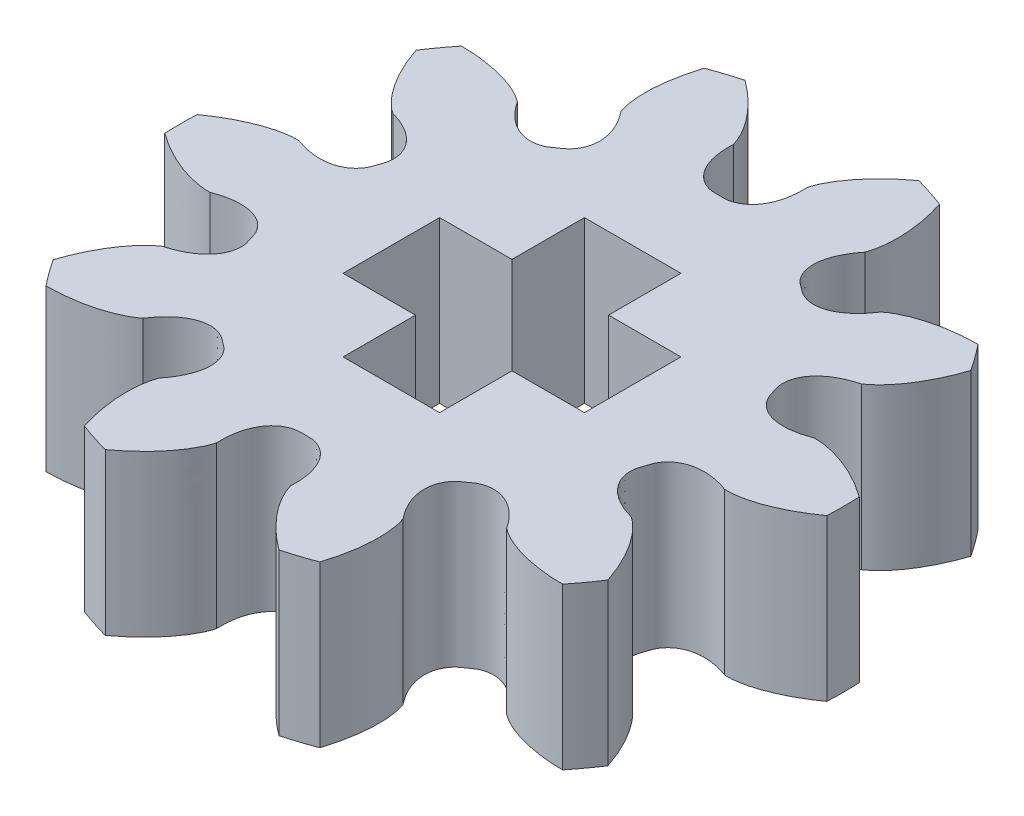
from build123d import *

# Parameters (mm, degrees)
BOSS_EXTRUDE1_DEPTH = 3


with BuildPart() as part:
    # Sketch1 → Boss-Extrude1 (new body)
    with BuildSketch(Plane(origin=(0, 0, 0), x_dir=(1, 0, 0), z_dir=(0, 1, 0))):
        with BuildLine():
            ThreePointArc((-2.195246041, -5.776962421), (-1.909725025, -5.877529271), (-1.61962196, -5.963994023))
            add(Edge.make_bspline(
                [(-1.61962196, -5.963994023), (-1.56984541, -5.926389713), (-1.470292055, -5.851180902), (-1.328761717, -5.728585248), (-1.193841186, -5.598826433), (-1.067209813, -5.460903424), (-0.950188009, -5.314730698), (-0.862420789, -5.185625903), (-0.799625352, -5.077784513), (-0.757179661, -4.994397549), (-0.719216402, -4.908719156), (-0.701057464, -4.849011857), (-0.691979526, -4.819163245)],
                knots=[0, 0, 0, 0, 0.010251706, 0.020503464, 0.030755047, 0.041006321, 0.051257106, 0.061507029, 0.066633012, 0.071758798, 0.07688417, 0.082007812, 0.082007812, 0.082007812, 0.082007812], degree=3, weights=[1, 1, 1, 1, 1, 1, 1, 1, 1, 1, 1, 1, 1]))
            add(Edge.make_bspline(
                [(-0.691979526, -4.819163245), (-0.692972091, -4.791041216), (-0.694957195, -4.734797907), (-0.692841973, -4.650377022), (-0.686110642, -4.566172646), (-0.672709266, -4.482813678), (-0.656279018, -4.399951189), (-0.631093663, -4.319279083), (-0.600480092, -4.240553587), (-0.562043943, -4.165226452), (-0.515300654, -4.094752352), (-0.460694656, -4.030167229), (-0.397849492, -3.973436024), (-0.327051342, -3.927084247), (-0.250353587, -3.891173269), (-0.182193787, -3.872913739), (-0.126636908, -3.863689308), (-0.070311712, -3.861657298), (0, -3.863061836), (0.070311712, -3.861657298), (0.126636908, -3.863689308), (0.182193787, -3.872913739), (0.250353587, -3.891173269), (0.327051342, -3.927084247), (0.397849492, -3.973436024), (0.460694656, -4.030167229), (0.515300654, -4.094752352), (0.562043943, -4.165226452), (0.600480092, -4.240553587), (0.631093663, -4.319279083), (0.656279018, -4.399951189), (0.672709266, -4.482813678), (0.686110642, -4.566172646), (0.692841973, -4.650377022), (0.694957195, -4.734797907), (0.692972091, -4.791041216), (0.691979526, -4.819163245)],
                knots=[0, 0, 0, 0, 0.003643402, 0.007286706, 0.010929975, 0.01457286, 0.01821558, 0.021858686, 0.025500936, 0.029144127, 0.032787024, 0.036428762, 0.040069815, 0.043709849, 0.04734977, 0.050988094, 0.052810356, 0.054631699, 0.058275045, 0.061918391, 0.063739733, 0.065561995, 0.069200319, 0.07284024, 0.076480275, 0.080121327, 0.083763065, 0.087405962, 0.091049153, 0.094691403, 0.098334509, 0.101977229, 0.105620114, 0.109263383, 0.112906688, 0.116550089, 0.116550089, 0.116550089, 0.116550089], degree=3, weights=[1, 1, 1, 1, 1, 1, 1, 1, 1, 1, 1, 1, 1, 1, 1, 1, 1, 1, 1, 1, 1, 1, 1, 1, 1, 1, 1, 1, 1, 1, 1, 1, 1, 1, 1, 1, 1]))
            add(Edge.make_bspline(
                [(0.691979526, -4.819163245), (0.701057464, -4.849011857), (0.719216402, -4.908719156), (0.757179661, -4.994397549), (0.799625352, -5.077784513), (0.862420789, -5.185625903), (0.950188009, -5.314730698), (1.067209813, -5.460903424), (1.193841186, -5.598826433), (1.328761717, -5.728585248), (1.470292055, -5.851180902), (1.56984541, -5.926389713), (1.61962196, -5.963994023)],
                knots=[0, 0, 0, 0, 0.002373455, 0.004747711, 0.007122158, 0.009496697, 0.014244829, 0.01899336, 0.023742117, 0.028491018, 0.03324, 0.037988957, 0.037988957, 0.037988957, 0.037988957], degree=3, weights=[1, 1, 1, 1, 1, 1, 1, 1, 1, 1, 1, 1, 1]))
            ThreePointArc((1.61962196, -5.963994023), (1.909725025, -5.877529271), (2.195246041, -5.776962421))
            add(Edge.make_bspline(
                [(2.195246041, -5.776962421), (2.213412858, -5.717281974), (2.249746584, -5.597920774), (2.292187114, -5.415549361), (2.3250698, -5.231267976), (2.346447621, -5.045253864), (2.355202077, -4.858213954), (2.350321355, -4.702177703), (2.337736353, -4.578021954), (2.32306201, -4.485611532), (2.303414436, -4.393982012), (2.283010256, -4.335004236), (2.272809887, -4.305520324)],
                knots=[0, 0, 0, 0, 0.018166013, 0.036332118, 0.054497913, 0.072663161, 0.090827541, 0.108990394, 0.11807363, 0.127156519, 0.136238672, 0.145317761, 0.145317761, 0.145317761, 0.145317761], degree=3, weights=[1, 1, 1, 1, 1, 1, 1, 1, 1, 1, 1, 1, 1]))
            add(Edge.make_bspline(
                [(2.272809887, -4.305520324), (2.255477171, -4.28335254), (2.220812201, -4.239017561), (2.1729021, -4.169476335), (2.128853771, -4.097396987), (2.09069854, -4.022081034), (2.055285541, -3.945386415), (2.028243047, -3.86531773), (2.006736261, -3.78363326), (1.99355558, -3.700100126), (1.989948058, -3.615610366), (1.996163056, -3.531263303), (2.013660096, -3.448427333), (2.043692111, -3.369313849), (2.084633955, -3.295179449), (2.129043709, -3.240343854), (2.168568184, -3.200225618), (2.212941839, -3.165474568), (2.270650776, -3.125282675), (2.326708579, -3.082818193), (2.373471005, -3.051355004), (2.42383945, -3.026162211), (2.489714569, -3.000871156), (2.572872298, -2.984841938), (2.657394096, -2.980727206), (2.741582667, -2.989684254), (2.823722031, -3.009838116), (2.902961782, -3.039377844), (2.978333459, -3.077726575), (3.049374044, -3.123422634), (3.117167299, -3.173884158), (3.179164997, -3.231263862), (3.23900411, -3.290825553), (3.293943962, -3.354991747), (3.345276563, -3.422046381), (3.376729568, -3.468714989), (3.39245628, -3.492049603)],
                knots=[0, 0, 0, 0, 0.008194405, 0.016388591, 0.024582696, 0.03277594, 0.040968812, 0.04916255, 0.057354364, 0.065548295, 0.073741565, 0.081932227, 0.090121349, 0.09830818, 0.106494756, 0.114677741, 0.118776206, 0.122872602, 0.131066881, 0.139261161, 0.143357557, 0.147456021, 0.155639006, 0.163825582, 0.172012413, 0.180201535, 0.188392198, 0.196585467, 0.204779398, 0.212971212, 0.221164951, 0.229357823, 0.237551066, 0.245745171, 0.253939358, 0.262133762, 0.262133762, 0.262133762, 0.262133762], degree=3, weights=[1, 1, 1, 1, 1, 1, 1, 1, 1, 1, 1, 1, 1, 1, 1, 1, 1, 1, 1, 1, 1, 1, 1, 1, 1, 1, 1, 1, 1, 1, 1, 1, 1, 1, 1, 1, 1]))
            add(Edge.make_bspline(
                [(3.39245628, -3.492049603), (3.41734506, -3.51086176), (3.467131019, -3.548492423), (3.548204437, -3.595493456), (3.63155735, -3.638005976), (3.745747504, -3.688341261), (3.892638571, -3.741200956), (4.073229372, -3.790673485), (4.256745415, -3.827823491), (4.442168736, -3.853496278), (4.628729102, -3.869488801), (4.753476088, -3.871818013), (4.815849422, -3.872982616)],
                knots=[0, 0, 0, 0, 0.009079089, 0.018161243, 0.027244131, 0.036327367, 0.05449022, 0.072654601, 0.090819848, 0.108985643, 0.127151749, 0.145317761, 0.145317761, 0.145317761, 0.145317761], degree=3, weights=[1, 1, 1, 1, 1, 1, 1, 1, 1, 1, 1, 1, 1]))
            ThreePointArc((4.815849422, -3.872982616), (4.999725025, -3.632512859), (5.171604669, -3.383327527))
            add(Edge.make_bspline(
                [(5.171604669, -3.383327527), (5.151222645, -3.324366843), (5.110458494, -3.206445175), (5.037598377, -3.033957685), (4.955883148, -2.865542955), (4.863841818, -2.70248881), (4.76098502, -2.546024604), (4.665320626, -2.422657442), (4.582162227, -2.32961061), (4.515972951, -2.26347437), (4.446219249, -2.200893085), (4.395045654, -2.165172339), (4.369463173, -2.147314979)],
                knots=[0, 0, 0, 0, 0.018166013, 0.036332118, 0.054497913, 0.072663161, 0.090827541, 0.108990394, 0.11807363, 0.127156519, 0.136238672, 0.145317761, 0.145317761, 0.145317761, 0.145317761], degree=3, weights=[1, 1, 1, 1, 1, 1, 1, 1, 1, 1, 1, 1, 1]))
            add(Edge.make_bspline(
                [(4.369463173, -2.147314979), (4.342410816, -2.13956878), (4.288306819, -2.124076587), (4.208671426, -2.095977404), (4.130668401, -2.063554944), (4.055530564, -2.02505014), (3.98180088, -1.983818129), (3.912859851, -1.934936381), (3.847447569, -1.881493628), (3.787684629, -1.821661313), (3.735104248, -1.75542811), (3.690554327, -1.683536818), (3.656019968, -1.606236609), (3.63381464, -1.52458008), (3.623362181, -1.440539079), (3.627058872, -1.370072752), (3.635453937, -1.314384514), (3.650926823, -1.260188143), (3.673990132, -1.193751758), (3.69438185, -1.126447319), (3.71371985, -1.073506801), (3.739660825, -1.023519574), (3.778089207, -0.964338258), (3.835943485, -0.902491461), (3.901904477, -0.849481906), (3.975279283, -0.807243509), (4.053577567, -0.77526802), (4.135046889, -0.752590205), (4.218564675, -0.73931262), (4.302897184, -0.734524899), (4.38740362, -0.735501255), (4.471287755, -0.745481078), (4.554708098, -0.75849495), (4.636871315, -0.778113657), (4.717813986, -0.802189449), (4.770691121, -0.821457534), (4.79713004, -0.831091704)],
                knots=[0, 0, 0, 0, 0.008194405, 0.016388591, 0.024582696, 0.03277594, 0.040968812, 0.04916255, 0.057354364, 0.065548295, 0.073741565, 0.081932227, 0.090121349, 0.09830818, 0.106494756, 0.114677741, 0.118776206, 0.122872602, 0.131066881, 0.139261161, 0.143357557, 0.147456021, 0.155639006, 0.163825582, 0.172012413, 0.180201535, 0.188392198, 0.196585467, 0.204779398, 0.212971212, 0.221164951, 0.229357823, 0.237551066, 0.245745171, 0.253939358, 0.262133762, 0.262133762, 0.262133762, 0.262133762], degree=3, weights=[1, 1, 1, 1, 1, 1, 1, 1, 1, 1, 1, 1, 1, 1, 1, 1, 1, 1, 1, 1, 1, 1, 1, 1, 1, 1, 1, 1, 1, 1, 1, 1, 1, 1, 1, 1, 1]))
            add(Edge.make_bspline(
                [(4.79713004, -0.831091704), (4.828322995, -0.831681801), (4.89071943, -0.832862194), (4.983935717, -0.823233069), (5.076357873, -0.808632807), (5.198325986, -0.782235619), (5.348233505, -0.738659608), (5.523413755, -0.672535115), (5.693717578, -0.594722077), (5.858818282, -0.506502705), (6.019148957, -0.409783497), (6.121440465, -0.33834343), (6.172586089, -0.302623488)],
                knots=[0, 0, 0, 0, 0.009079089, 0.018161243, 0.027244131, 0.036327367, 0.05449022, 0.072654601, 0.090819848, 0.108985643, 0.127151749, 0.145317761, 0.145317761, 0.145317761, 0.145317761], degree=3, weights=[1, 1, 1, 1, 1, 1, 1, 1, 1, 1, 1, 1, 1]))
            ThreePointArc((6.172586089, -0.302623488), (6.18, 0), (6.172586089, 0.302623488))
            add(Edge.make_bspline(
                [(6.172586089, 0.302623488), (6.121440465, 0.33834343), (6.019148957, 0.409783497), (5.858818282, 0.506502705), (5.693717578, 0.594722077), (5.523413755, 0.672535115), (5.348233505, 0.738659608), (5.198325986, 0.782235619), (5.076357873, 0.808632807), (4.983935717, 0.823233069), (4.89071943, 0.832862194), (4.828322995, 0.831681801), (4.79713004, 0.831091704)],
                knots=[0, 0, 0, 0, 0.018166013, 0.036332118, 0.054497913, 0.072663161, 0.090827541, 0.108990394, 0.11807363, 0.127156519, 0.136238672, 0.145317761, 0.145317761, 0.145317761, 0.145317761], degree=3, weights=[1, 1, 1, 1, 1, 1, 1, 1, 1, 1, 1, 1, 1]))
            add(Edge.make_bspline(
                [(4.79713004, 0.831091704), (4.770691121, 0.821457534), (4.717813986, 0.802189449), (4.636871315, 0.778113657), (4.554708098, 0.75849495), (4.471287755, 0.745481078), (4.38740362, 0.735501255), (4.302897184, 0.734524899), (4.218564675, 0.73931262), (4.135046889, 0.752590205), (4.053577567, 0.77526802), (3.975279283, 0.807243509), (3.901904477, 0.849481906), (3.835943485, 0.902491461), (3.778089207, 0.964338258), (3.739660825, 1.023519574), (3.71371985, 1.073506801), (3.69438185, 1.126447319), (3.673990132, 1.193751758), (3.650926823, 1.260188143), (3.635453937, 1.314384514), (3.627058872, 1.370072752), (3.623362181, 1.440539079), (3.63381464, 1.52458008), (3.656019968, 1.606236609), (3.690554327, 1.683536818), (3.735104248, 1.75542811), (3.787684629, 1.821661313), (3.847447569, 1.881493628), (3.912859851, 1.934936381), (3.98180088, 1.983818129), (4.055530564, 2.02505014), (4.130668401, 2.063554944), (4.208671426, 2.095977404), (4.288306819, 2.124076587), (4.342410816, 2.13956878), (4.369463173, 2.147314979)],
                knots=[0, 0, 0, 0, 0.008194405, 0.016388591, 0.024582696, 0.03277594, 0.040968812, 0.04916255, 0.057354364, 0.065548295, 0.073741565, 0.081932227, 0.090121349, 0.09830818, 0.106494756, 0.114677741, 0.118776206, 0.122872602, 0.131066881, 0.139261161, 0.143357557, 0.147456021, 0.155639006, 0.163825582, 0.172012413, 0.180201535, 0.188392198, 0.196585467, 0.204779398, 0.212971212, 0.221164951, 0.229357823, 0.237551066, 0.245745171, 0.253939358, 0.262133762, 0.262133762, 0.262133762, 0.262133762], degree=3, weights=[1, 1, 1, 1, 1, 1, 1, 1, 1, 1, 1, 1, 1, 1, 1, 1, 1, 1, 1, 1, 1, 1, 1, 1, 1, 1, 1, 1, 1, 1, 1, 1, 1, 1, 1, 1, 1]))
            add(Edge.make_bspline(
                [(4.369463173, 2.147314979), (4.395045654, 2.165172339), (4.446219249, 2.200893085), (4.515972951, 2.26347437), (4.582162227, 2.32961061), (4.665320626, 2.422657442), (4.76098502, 2.546024604), (4.863841818, 2.70248881), (4.955883148, 2.865542955), (5.037598377, 3.033957685), (5.110458494, 3.206445175), (5.151222645, 3.324366843), (5.171604669, 3.383327527)],
                knots=[0, 0, 0, 0, 0.009079089, 0.018161243, 0.027244131, 0.036327367, 0.05449022, 0.072654601, 0.090819848, 0.108985643, 0.127151749, 0.145317761, 0.145317761, 0.145317761, 0.145317761], degree=3, weights=[1, 1, 1, 1, 1, 1, 1, 1, 1, 1, 1, 1, 1]))
            ThreePointArc((5.171604669, 3.383327527), (4.999725025, 3.632512859), (4.815849422, 3.872982616))
            add(Edge.make_bspline(
                [(4.815849422, 3.872982616), (4.753476088, 3.871818013), (4.628729102, 3.869488801), (4.442168736, 3.853496278), (4.256745415, 3.827823491), (4.073229372, 3.790673485), (3.892638571, 3.741200956), (3.745747504, 3.688341261), (3.63155735, 3.638005976), (3.548204437, 3.595493456), (3.467131019, 3.548492423), (3.41734506, 3.51086176), (3.39245628, 3.492049603)],
                knots=[0, 0, 0, 0, 0.018166013, 0.036332118, 0.054497913, 0.072663161, 0.090827541, 0.108990394, 0.11807363, 0.127156519, 0.136238672, 0.145317761, 0.145317761, 0.145317761, 0.145317761], degree=3, weights=[1, 1, 1, 1, 1, 1, 1, 1, 1, 1, 1, 1, 1]))
            add(Edge.make_bspline(
                [(3.39245628, 3.492049603), (3.376729568, 3.468714989), (3.345276563, 3.422046381), (3.293943962, 3.354991747), (3.23900411, 3.290825553), (3.179164997, 3.231263862), (3.117167299, 3.173884158), (3.049374044, 3.123422634), (2.978333459, 3.077726575), (2.902961782, 3.039377844), (2.823722031, 3.009838116), (2.741582667, 2.989684254), (2.657394096, 2.980727206), (2.572872298, 2.984841938), (2.489714569, 3.000871156), (2.42383945, 3.026162211), (2.373471005, 3.051355004), (2.326708579, 3.082818193), (2.270650776, 3.125282675), (2.212941839, 3.165474568), (2.168568184, 3.200225618), (2.129043709, 3.240343854), (2.084633955, 3.295179449), (2.043692111, 3.369313849), (2.013660096, 3.448427333), (1.996163056, 3.531263303), (1.989948058, 3.615610366), (1.99355558, 3.700100126), (2.006736261, 3.78363326), (2.028243047, 3.86531773), (2.055285541, 3.945386415), (2.09069854, 4.022081034), (2.128853771, 4.097396987), (2.1729021, 4.169476335), (2.220812201, 4.239017561), (2.255477171, 4.28335254), (2.272809887, 4.305520324)],
                knots=[0, 0, 0, 0, 0.008194405, 0.016388591, 0.024582696, 0.03277594, 0.040968812, 0.04916255, 0.057354364, 0.065548295, 0.073741565, 0.081932227, 0.090121349, 0.09830818, 0.106494756, 0.114677741, 0.118776206, 0.122872602, 0.131066881, 0.139261161, 0.143357557, 0.147456021, 0.155639006, 0.163825582, 0.172012413, 0.180201535, 0.188392198, 0.196585467, 0.204779398, 0.212971212, 0.221164951, 0.229357823, 0.237551066, 0.245745171, 0.253939358, 0.262133762, 0.262133762, 0.262133762, 0.262133762], degree=3, weights=[1, 1, 1, 1, 1, 1, 1, 1, 1, 1, 1, 1, 1, 1, 1, 1, 1, 1, 1, 1, 1, 1, 1, 1, 1, 1, 1, 1, 1, 1, 1, 1, 1, 1, 1, 1, 1]))
            add(Edge.make_bspline(
                [(2.272809887, 4.305520324), (2.283010256, 4.335004236), (2.303414436, 4.393982012), (2.32306201, 4.485611532), (2.337736353, 4.578021954), (2.350321355, 4.702177703), (2.355202077, 4.858213954), (2.346447621, 5.045253864), (2.3250698, 5.231267976), (2.292187114, 5.415549361), (2.249746584, 5.597920774), (2.213412858, 5.717281974), (2.195246041, 5.776962421)],
                knots=[0, 0, 0, 0, 0.009079089, 0.018161243, 0.027244131, 0.036327367, 0.05449022, 0.072654601, 0.090819848, 0.108985643, 0.127151749, 0.145317761, 0.145317761, 0.145317761, 0.145317761], degree=3, weights=[1, 1, 1, 1, 1, 1, 1, 1, 1, 1, 1, 1, 1]))
            ThreePointArc((2.195246041, 5.776962421), (1.909725025, 5.877529271), (1.61962196, 5.963994023))
            add(Edge.make_bspline(
                [(1.61962196, 5.963994023), (1.56984541, 5.926389713), (1.470292055, 5.851180902), (1.328761717, 5.728585248), (1.193841186, 5.598826433), (1.067209813, 5.460903424), (0.950188009, 5.314730698), (0.862420789, 5.185625903), (0.799625352, 5.077784513), (0.757179661, 4.994397549), (0.719216402, 4.908719156), (0.701057464, 4.849011857), (0.691979526, 4.819163245)],
                knots=[0, 0, 0, 0, 0.018166013, 0.036332118, 0.054497913, 0.072663161, 0.090827541, 0.108990394, 0.11807363, 0.127156519, 0.136238672, 0.145317761, 0.145317761, 0.145317761, 0.145317761], degree=3, weights=[1, 1, 1, 1, 1, 1, 1, 1, 1, 1, 1, 1, 1]))
            add(Edge.make_bspline(
                [(0.691979526, 4.819163245), (0.692972091, 4.791041216), (0.694957195, 4.734797907), (0.692841973, 4.650377022), (0.686110642, 4.566172646), (0.672709266, 4.482813678), (0.656279018, 4.399951189), (0.631093663, 4.319279083), (0.600480092, 4.240553587), (0.562043943, 4.165226452), (0.515300654, 4.094752352), (0.460694656, 4.030167229), (0.397849492, 3.973436024), (0.327051342, 3.927084247), (0.250353587, 3.891173269), (0.182193787, 3.872913739), (0.126636908, 3.863689308), (0.070311712, 3.861657298), (0, 3.863061836), (-0.070311712, 3.861657298), (-0.126636908, 3.863689308), (-0.182193787, 3.872913739), (-0.250353587, 3.891173269), (-0.327051342, 3.927084247), (-0.397849492, 3.973436024), (-0.460694656, 4.030167229), (-0.515300654, 4.094752352), (-0.562043943, 4.165226452), (-0.600480092, 4.240553587), (-0.631093663, 4.319279083), (-0.656279018, 4.399951189), (-0.672709266, 4.482813678), (-0.686110642, 4.566172646), (-0.692841973, 4.650377022), (-0.694957195, 4.734797907), (-0.692972091, 4.791041216), (-0.691979526, 4.819163245)],
                knots=[0, 0, 0, 0, 0.008194405, 0.016388591, 0.024582696, 0.03277594, 0.040968812, 0.04916255, 0.057354364, 0.065548295, 0.073741565, 0.081932227, 0.090121349, 0.09830818, 0.106494756, 0.114677741, 0.118776206, 0.122872602, 0.131066881, 0.139261161, 0.143357557, 0.147456021, 0.155639006, 0.163825582, 0.172012413, 0.180201535, 0.188392198, 0.196585467, 0.204779398, 0.212971212, 0.221164951, 0.229357823, 0.237551066, 0.245745171, 0.253939358, 0.262133762, 0.262133762, 0.262133762, 0.262133762], degree=3, weights=[1, 1, 1, 1, 1, 1, 1, 1, 1, 1, 1, 1, 1, 1, 1, 1, 1, 1, 1, 1, 1, 1, 1, 1, 1, 1, 1, 1, 1, 1, 1, 1, 1, 1, 1, 1, 1]))
            add(Edge.make_bspline(
                [(-0.691979526, 4.819163245), (-0.701057464, 4.849011857), (-0.719216402, 4.908719156), (-0.757179661, 4.994397549), (-0.799625352, 5.077784513), (-0.862420789, 5.185625903), (-0.950188009, 5.314730698), (-1.067209813, 5.460903424), (-1.193841186, 5.598826433), (-1.328761717, 5.728585248), (-1.470292055, 5.851180902), (-1.56984541, 5.926389713), (-1.61962196, 5.963994023)],
                knots=[0, 0, 0, 0, 0.009079089, 0.018161243, 0.027244131, 0.036327367, 0.05449022, 0.072654601, 0.090819848, 0.108985643, 0.127151749, 0.145317761, 0.145317761, 0.145317761, 0.145317761], degree=3, weights=[1, 1, 1, 1, 1, 1, 1, 1, 1, 1, 1, 1, 1]))
            ThreePointArc((-1.61962196, 5.963994023), (-1.909725025, 5.877529271), (-2.195246041, 5.776962421))
            add(Edge.make_bspline(
                [(-2.195246041, 5.776962421), (-2.213412858, 5.717281974), (-2.249746584, 5.597920774), (-2.292187114, 5.415549361), (-2.3250698, 5.231267976), (-2.346447621, 5.045253864), (-2.355202077, 4.858213954), (-2.350321355, 4.702177703), (-2.337736353, 4.578021954), (-2.32306201, 4.485611532), (-2.303414436, 4.393982012), (-2.283010256, 4.335004236), (-2.272809887, 4.305520324)],
                knots=[0, 0, 0, 0, 0.018166013, 0.036332118, 0.054497913, 0.072663161, 0.090827541, 0.108990394, 0.11807363, 0.127156519, 0.136238672, 0.145317761, 0.145317761, 0.145317761, 0.145317761], degree=3, weights=[1, 1, 1, 1, 1, 1, 1, 1, 1, 1, 1, 1, 1]))
            add(Edge.make_bspline(
                [(-2.272809887, 4.305520324), (-2.255477171, 4.28335254), (-2.220812201, 4.239017561), (-2.1729021, 4.169476335), (-2.128853771, 4.097396987), (-2.09069854, 4.022081034), (-2.055285541, 3.945386415), (-2.028243047, 3.86531773), (-2.006736261, 3.78363326), (-1.99355558, 3.700100126), (-1.989948058, 3.615610366), (-1.996163056, 3.531263303), (-2.013660096, 3.448427333), (-2.043692111, 3.369313849), (-2.084633955, 3.295179449), (-2.129043709, 3.240343854), (-2.168568184, 3.200225618), (-2.212941839, 3.165474568), (-2.270650776, 3.125282675), (-2.326708579, 3.082818193), (-2.373471005, 3.051355004), (-2.42383945, 3.026162211), (-2.489714569, 3.000871156), (-2.572872298, 2.984841938), (-2.657394096, 2.980727206), (-2.741582667, 2.989684254), (-2.823722031, 3.009838116), (-2.902961782, 3.039377844), (-2.978333459, 3.077726575), (-3.049374044, 3.123422634), (-3.117167299, 3.173884158), (-3.179164997, 3.231263862), (-3.23900411, 3.290825553), (-3.293943962, 3.354991747), (-3.345276563, 3.422046381), (-3.376729568, 3.468714989), (-3.39245628, 3.492049603)],
                knots=[0, 0, 0, 0, 0.008194405, 0.016388591, 0.024582696, 0.03277594, 0.040968812, 0.04916255, 0.057354364, 0.065548295, 0.073741565, 0.081932227, 0.090121349, 0.09830818, 0.106494756, 0.114677741, 0.118776206, 0.122872602, 0.131066881, 0.139261161, 0.143357557, 0.147456021, 0.155639006, 0.163825582, 0.172012413, 0.180201535, 0.188392198, 0.196585467, 0.204779398, 0.212971212, 0.221164951, 0.229357823, 0.237551066, 0.245745171, 0.253939358, 0.262133762, 0.262133762, 0.262133762, 0.262133762], degree=3, weights=[1, 1, 1, 1, 1, 1, 1, 1, 1, 1, 1, 1, 1, 1, 1, 1, 1, 1, 1, 1, 1, 1, 1, 1, 1, 1, 1, 1, 1, 1, 1, 1, 1, 1, 1, 1, 1]))
            add(Edge.make_bspline(
                [(-3.39245628, 3.492049603), (-3.41734506, 3.51086176), (-3.467131019, 3.548492423), (-3.548204437, 3.595493456), (-3.63155735, 3.638005976), (-3.745747504, 3.688341261), (-3.892638571, 3.741200956), (-4.073229372, 3.790673485), (-4.256745415, 3.827823491), (-4.442168736, 3.853496278), (-4.628729102, 3.869488801), (-4.753476088, 3.871818013), (-4.815849422, 3.872982616)],
                knots=[0, 0, 0, 0, 0.009079089, 0.018161243, 0.027244131, 0.036327367, 0.05449022, 0.072654601, 0.090819848, 0.108985643, 0.127151749, 0.145317761, 0.145317761, 0.145317761, 0.145317761], degree=3, weights=[1, 1, 1, 1, 1, 1, 1, 1, 1, 1, 1, 1, 1]))
            ThreePointArc((-4.815849422, 3.872982616), (-4.999725025, 3.632512859), (-5.171604669, 3.383327527))
            add(Edge.make_bspline(
                [(-5.171604669, 3.383327527), (-5.151222645, 3.324366843), (-5.110458494, 3.206445175), (-5.037598377, 3.033957685), (-4.955883148, 2.865542955), (-4.863841818, 2.70248881), (-4.76098502, 2.546024604), (-4.665320626, 2.422657442), (-4.582162227, 2.32961061), (-4.515972951, 2.26347437), (-4.446219249, 2.200893085), (-4.395045654, 2.165172339), (-4.369463173, 2.147314979)],
                knots=[0, 0, 0, 0, 0.018166013, 0.036332118, 0.054497913, 0.072663161, 0.090827541, 0.108990394, 0.11807363, 0.127156519, 0.136238672, 0.145317761, 0.145317761, 0.145317761, 0.145317761], degree=3, weights=[1, 1, 1, 1, 1, 1, 1, 1, 1, 1, 1, 1, 1]))
            add(Edge.make_bspline(
                [(-4.369463173, 2.147314979), (-4.342410816, 2.13956878), (-4.288306819, 2.124076587), (-4.208671426, 2.095977404), (-4.130668401, 2.063554944), (-4.055530564, 2.02505014), (-3.98180088, 1.983818129), (-3.912859851, 1.934936381), (-3.847447569, 1.881493628), (-3.787684629, 1.821661313), (-3.735104248, 1.75542811), (-3.690554327, 1.683536818), (-3.656019968, 1.606236609), (-3.63381464, 1.52458008), (-3.623362181, 1.440539079), (-3.627058872, 1.370072752), (-3.635453937, 1.314384514), (-3.650926823, 1.260188143), (-3.673990132, 1.193751758), (-3.69438185, 1.126447319), (-3.71371985, 1.073506801), (-3.739660825, 1.023519574), (-3.778089207, 0.964338258), (-3.835943485, 0.902491461), (-3.901904477, 0.849481906), (-3.975279283, 0.807243509), (-4.053577567, 0.77526802), (-4.135046889, 0.752590205), (-4.218564675, 0.73931262), (-4.302897184, 0.734524899), (-4.38740362, 0.735501255), (-4.471287755, 0.745481078), (-4.554708098, 0.75849495), (-4.636871315, 0.778113657), (-4.717813986, 0.802189449), (-4.770691121, 0.821457534), (-4.79713004, 0.831091704)],
                knots=[0, 0, 0, 0, 0.008194405, 0.016388591, 0.024582696, 0.03277594, 0.040968812, 0.04916255, 0.057354364, 0.065548295, 0.073741565, 0.081932227, 0.090121349, 0.09830818, 0.106494756, 0.114677741, 0.118776206, 0.122872602, 0.131066881, 0.139261161, 0.143357557, 0.147456021, 0.155639006, 0.163825582, 0.172012413, 0.180201535, 0.188392198, 0.196585467, 0.204779398, 0.212971212, 0.221164951, 0.229357823, 0.237551066, 0.245745171, 0.253939358, 0.262133762, 0.262133762, 0.262133762, 0.262133762], degree=3, weights=[1, 1, 1, 1, 1, 1, 1, 1, 1, 1, 1, 1, 1, 1, 1, 1, 1, 1, 1, 1, 1, 1, 1, 1, 1, 1, 1, 1, 1, 1, 1, 1, 1, 1, 1, 1, 1]))
            add(Edge.make_bspline(
                [(-4.79713004, 0.831091704), (-4.828322995, 0.831681801), (-4.89071943, 0.832862194), (-4.983935717, 0.823233069), (-5.076357873, 0.808632807), (-5.198325986, 0.782235619), (-5.348233505, 0.738659608), (-5.523413755, 0.672535115), (-5.693717578, 0.594722077), (-5.858818282, 0.506502705), (-6.019148957, 0.409783497), (-6.121440465, 0.33834343), (-6.172586089, 0.302623488)],
                knots=[0, 0, 0, 0, 0.009079089, 0.018161243, 0.027244131, 0.036327367, 0.05449022, 0.072654601, 0.090819848, 0.108985643, 0.127151749, 0.145317761, 0.145317761, 0.145317761, 0.145317761], degree=3, weights=[1, 1, 1, 1, 1, 1, 1, 1, 1, 1, 1, 1, 1]))
            ThreePointArc((-6.172586089, 0.302623488), (-6.18, 0), (-6.172586089, -0.302623488))
            add(Edge.make_bspline(
                [(-6.172586089, -0.302623488), (-6.121440465, -0.33834343), (-6.019148957, -0.409783497), (-5.858818282, -0.506502705), (-5.693717578, -0.594722077), (-5.523413755, -0.672535115), (-5.348233505, -0.738659608), (-5.198325986, -0.782235619), (-5.076357873, -0.808632807), (-4.983935717, -0.823233069), (-4.89071943, -0.832862194), (-4.828322995, -0.831681801), (-4.79713004, -0.831091704)],
                knots=[0, 0, 0, 0, 0.018166013, 0.036332118, 0.054497913, 0.072663161, 0.090827541, 0.108990394, 0.11807363, 0.127156519, 0.136238672, 0.145317761, 0.145317761, 0.145317761, 0.145317761], degree=3, weights=[1, 1, 1, 1, 1, 1, 1, 1, 1, 1, 1, 1, 1]))
            add(Edge.make_bspline(
                [(-4.79713004, -0.831091704), (-4.770691121, -0.821457534), (-4.717813986, -0.802189449), (-4.636871315, -0.778113657), (-4.554708098, -0.75849495), (-4.471287755, -0.745481078), (-4.38740362, -0.735501255), (-4.302897184, -0.734524899), (-4.218564675, -0.73931262), (-4.135046889, -0.752590205), (-4.053577567, -0.77526802), (-3.975279283, -0.807243509), (-3.901904477, -0.849481906), (-3.835943485, -0.902491461), (-3.778089207, -0.964338258), (-3.739660825, -1.023519574), (-3.71371985, -1.073506801), (-3.69438185, -1.126447319), (-3.673990132, -1.193751758), (-3.650926823, -1.260188143), (-3.635453937, -1.314384514), (-3.627058872, -1.370072752), (-3.623362181, -1.440539079), (-3.63381464, -1.52458008), (-3.656019968, -1.606236609), (-3.690554327, -1.683536818), (-3.735104248, -1.75542811), (-3.787684629, -1.821661313), (-3.847447569, -1.881493628), (-3.912859851, -1.934936381), (-3.98180088, -1.983818129), (-4.055530564, -2.02505014), (-4.130668401, -2.063554944), (-4.208671426, -2.095977404), (-4.288306819, -2.124076587), (-4.342410816, -2.13956878), (-4.369463173, -2.147314979)],
                knots=[0, 0, 0, 0, 0.008194405, 0.016388591, 0.024582696, 0.03277594, 0.040968812, 0.04916255, 0.057354364, 0.065548295, 0.073741565, 0.081932227, 0.090121349, 0.09830818, 0.106494756, 0.114677741, 0.118776206, 0.122872602, 0.131066881, 0.139261161, 0.143357557, 0.147456021, 0.155639006, 0.163825582, 0.172012413, 0.180201535, 0.188392198, 0.196585467, 0.204779398, 0.212971212, 0.221164951, 0.229357823, 0.237551066, 0.245745171, 0.253939358, 0.262133762, 0.262133762, 0.262133762, 0.262133762], degree=3, weights=[1, 1, 1, 1, 1, 1, 1, 1, 1, 1, 1, 1, 1, 1, 1, 1, 1, 1, 1, 1, 1, 1, 1, 1, 1, 1, 1, 1, 1, 1, 1, 1, 1, 1, 1, 1, 1]))
            add(Edge.make_bspline(
                [(-4.369463173, -2.147314979), (-4.395045654, -2.165172339), (-4.446219249, -2.200893085), (-4.515972951, -2.26347437), (-4.582162227, -2.32961061), (-4.665320626, -2.422657442), (-4.76098502, -2.546024604), (-4.863841818, -2.70248881), (-4.955883148, -2.865542955), (-5.037598377, -3.033957685), (-5.110458494, -3.206445175), (-5.151222645, -3.324366843), (-5.171604669, -3.383327527)],
                knots=[0, 0, 0, 0, 0.009079089, 0.018161243, 0.027244131, 0.036327367, 0.05449022, 0.072654601, 0.090819848, 0.108985643, 0.127151749, 0.145317761, 0.145317761, 0.145317761, 0.145317761], degree=3, weights=[1, 1, 1, 1, 1, 1, 1, 1, 1, 1, 1, 1, 1]))
            ThreePointArc((-5.171604669, -3.383327527), (-4.999725025, -3.632512859), (-4.815849422, -3.872982616))
            add(Edge.make_bspline(
                [(-4.815849422, -3.872982616), (-4.753476088, -3.871818013), (-4.628729102, -3.869488801), (-4.442168736, -3.853496278), (-4.256745415, -3.827823491), (-4.073229372, -3.790673485), (-3.892638571, -3.741200956), (-3.745747504, -3.688341261), (-3.63155735, -3.638005976), (-3.548204437, -3.595493456), (-3.467131019, -3.548492423), (-3.41734506, -3.51086176), (-3.39245628, -3.492049603)],
                knots=[0, 0, 0, 0, 0.018166013, 0.036332118, 0.054497913, 0.072663161, 0.090827541, 0.108990394, 0.11807363, 0.127156519, 0.136238672, 0.145317761, 0.145317761, 0.145317761, 0.145317761], degree=3, weights=[1, 1, 1, 1, 1, 1, 1, 1, 1, 1, 1, 1, 1]))
            add(Edge.make_bspline(
                [(-3.39245628, -3.492049603), (-3.376729568, -3.468714989), (-3.345276563, -3.422046381), (-3.293943962, -3.354991747), (-3.23900411, -3.290825553), (-3.179164997, -3.231263862), (-3.117167299, -3.173884158), (-3.049374044, -3.123422634), (-2.978333459, -3.077726575), (-2.902961782, -3.039377844), (-2.823722031, -3.009838116), (-2.741582667, -2.989684254), (-2.657394096, -2.980727206), (-2.572872298, -2.984841938), (-2.489714569, -3.000871156), (-2.42383945, -3.026162211), (-2.373471005, -3.051355004), (-2.326708579, -3.082818193), (-2.270650776, -3.125282675), (-2.212941839, -3.165474568), (-2.168568184, -3.200225618), (-2.129043709, -3.240343854), (-2.084633955, -3.295179449), (-2.043692111, -3.369313849), (-2.013660096, -3.448427333), (-1.996163056, -3.531263303), (-1.989948058, -3.615610366), (-1.99355558, -3.700100126), (-2.006736261, -3.78363326), (-2.028243047, -3.86531773), (-2.055285541, -3.945386415), (-2.09069854, -4.022081034), (-2.128853771, -4.097396987), (-2.1729021, -4.169476335), (-2.220812201, -4.239017561), (-2.255477171, -4.28335254), (-2.272809887, -4.305520324)],
                knots=[0, 0, 0, 0, 0.008194405, 0.016388591, 0.024582696, 0.03277594, 0.040968812, 0.04916255, 0.057354364, 0.065548295, 0.073741565, 0.081932227, 0.090121349, 0.09830818, 0.106494756, 0.114677741, 0.118776206, 0.122872602, 0.131066881, 0.139261161, 0.143357557, 0.147456021, 0.155639006, 0.163825582, 0.172012413, 0.180201535, 0.188392198, 0.196585467, 0.204779398, 0.212971212, 0.221164951, 0.229357823, 0.237551066, 0.245745171, 0.253939358, 0.262133762, 0.262133762, 0.262133762, 0.262133762], degree=3, weights=[1, 1, 1, 1, 1, 1, 1, 1, 1, 1, 1, 1, 1, 1, 1, 1, 1, 1, 1, 1, 1, 1, 1, 1, 1, 1, 1, 1, 1, 1, 1, 1, 1, 1, 1, 1, 1]))
            add(Edge.make_bspline(
                [(-2.272809887, -4.305520324), (-2.283010256, -4.335004236), (-2.303414436, -4.393982012), (-2.32306201, -4.485611532), (-2.337736353, -4.578021954), (-2.350321355, -4.702177703), (-2.355202077, -4.858213954), (-2.346447621, -5.045253864), (-2.3250698, -5.231267976), (-2.292187114, -5.415549361), (-2.249746584, -5.597920774), (-2.213412858, -5.717281974), (-2.195246041, -5.776962421)],
                knots=[0, 0, 0, 0, 0.009079089, 0.018161243, 0.027244131, 0.036327367, 0.05449022, 0.072654601, 0.090819848, 0.108985643, 0.127151749, 0.145317761, 0.145317761, 0.145317761, 0.145317761], degree=3, weights=[1, 1, 1, 1, 1, 1, 1, 1, 1, 1, 1, 1, 1]))
        make_face()
        Polygon((-2.25, 0.9), (-2.25, -0.9), (-0.9, -0.9), (-0.9, -2.25), (0.9, -2.25), (0.9, -0.9), (2.25, -0.9), (2.25, 0.9), (0.9, 0.9), (0.9, 2.25), (-0.9, 2.25), (-0.9, 0.9), align=None, mode=Mode.SUBTRACT)
    extrude(amount=BOSS_EXTRUDE1_DEPTH)


solid = part.part
